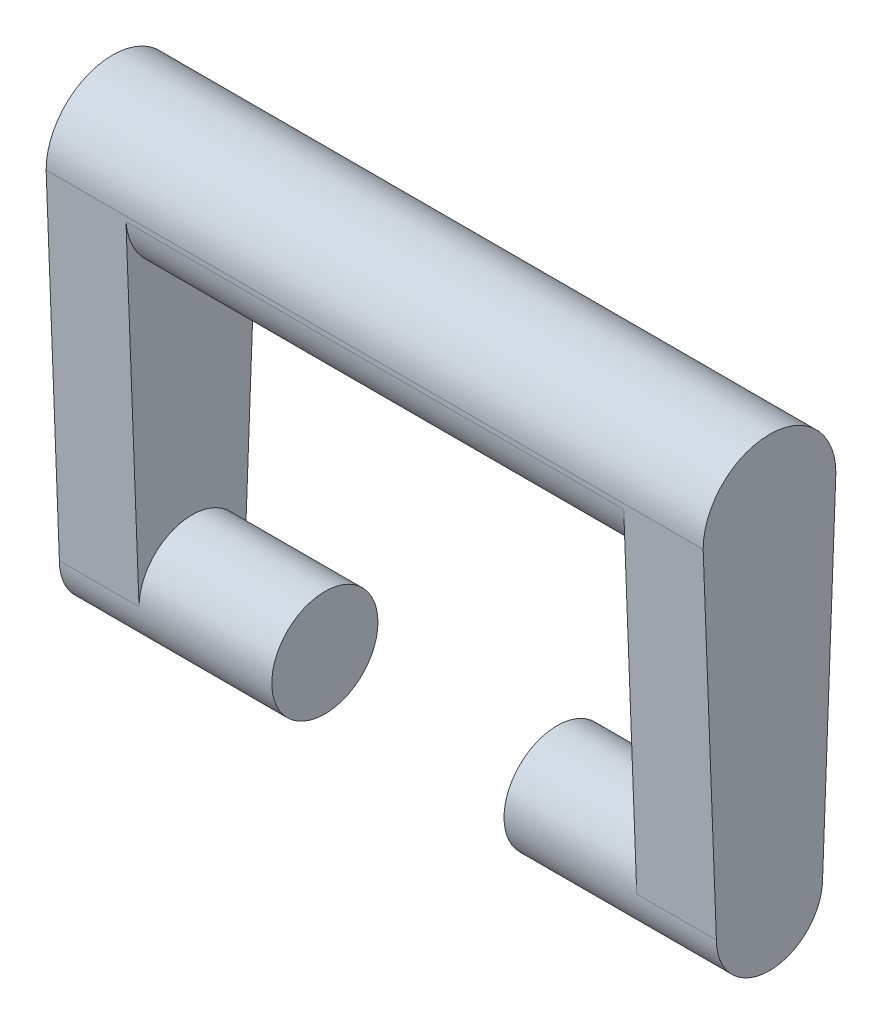
from build123d import *

# Parameters (mm, degrees)
BOSS_EXTRUDE4_DEPTH = 15.24
BOSS_EXTRUDE5_DEPTH = 62.865
SKETCH2_11_R        = 10.16
BOSS_EXTRUDE6_DEPTH = 40.64


with BuildPart() as part:
    # Sketch2 → Boss-Extrude4 (new body)
    with BuildSketch(Plane(origin=(0, 0, 0), x_dir=(0, 0, -1), z_dir=(1, 0, 0))):
        with BuildLine():
            Line((10.16, -34.29), (12.7, 31.75))
            ThreePointArc((12.7, 31.75), (0, 44.45), (-12.7, 31.75))
            Line((-12.7, 31.75), (-10.16, -34.29))
            ThreePointArc((-10.16, -34.29), (0, -44.45), (10.16, -34.29))
        make_face()
    extrude(amount=BOSS_EXTRUDE4_DEPTH)

    # Sketch2_9 → Boss-Extrude5 (add)
    with BuildSketch(Plane(origin=(0, 0, 0), x_dir=(0, 0, -1), z_dir=(1, 0, 0))):
        with BuildLine():
            Line((12.662481536, 30.774519941), (12.7, 31.75))
            ThreePointArc((12.7, 31.75), (8.98025611, 40.730256132), (-3e-08, 44.45))
            ThreePointArc((-3e-08, 44.45), (-8.980256132, 40.73025611), (-12.7, 31.75))
            Line((-12.7, 31.75), (-12.662481536, 30.774519941))
            ThreePointArc((-12.662481536, 30.774519941), (0, 19.05), (12.662481536, 30.774519941))
        make_face()
    extrude(amount=BOSS_EXTRUDE5_DEPTH)

    # Sketch2_11 → Boss-Extrude6 (add)
    with BuildSketch(Plane(origin=(0, 0, 0), x_dir=(0, 0, -1), z_dir=(1, 0, 0))):
        with Locations((0, -34.29)):
            Circle(SKETCH2_11_R)
    extrude(amount=BOSS_EXTRUDE6_DEPTH)

    # Mirror1: part across plane


with BuildPart() as part_1:
    add(part.part)
    add(part.part.mirror(Plane(origin=(62.865, 0, 0), x_dir=(0, 0, 1), z_dir=(1, 0, 0))))


solid = part_1.part
